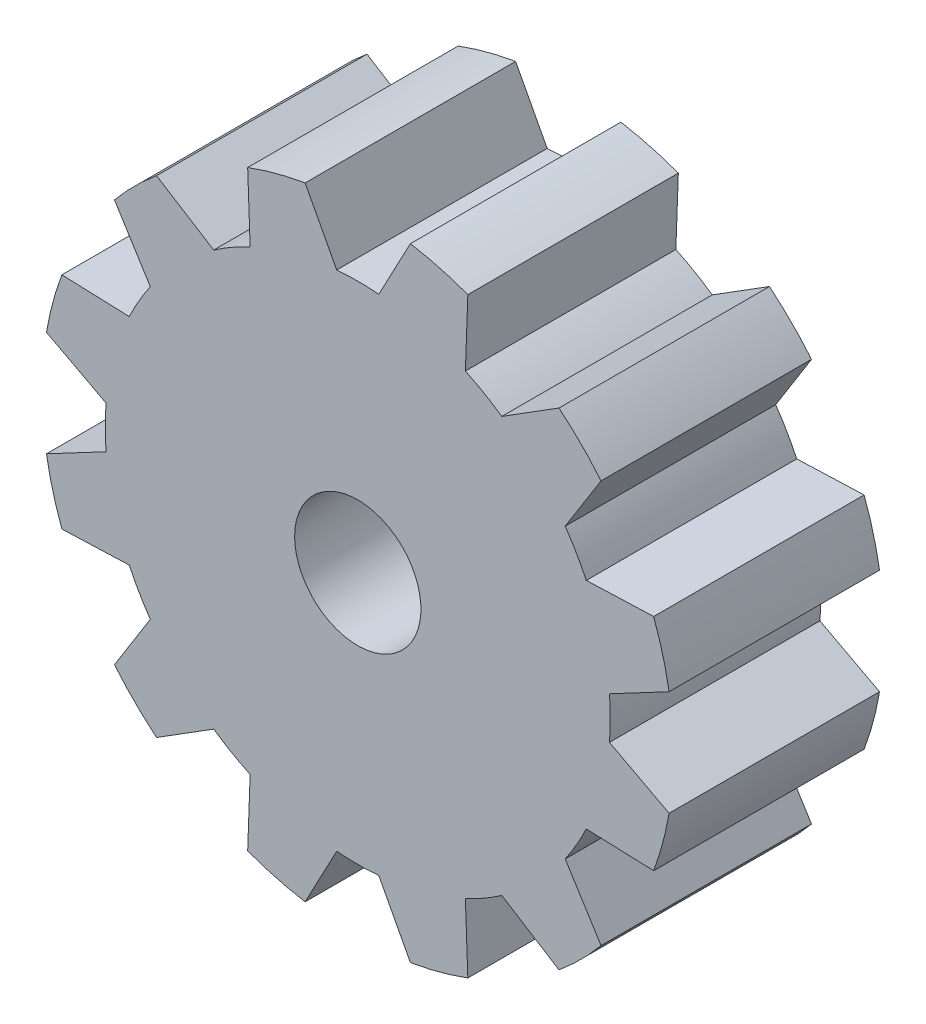
from build123d import *

# Parameters (mm, degrees)
SKETCH1_R           = 15
BOSS_EXTRUDE1_DEPTH = 10
CUT_EXTRUDE1_DEPTH  = 10
CIRPATTERN1_COUNT   = 12
SKETCH3_R           = 3
CUT_EXTRUDE2_DEPTH  = 11


with BuildPart() as part:
    # Sketch1 → Boss-Extrude1 (new body)
    with BuildSketch(Plane.XY):
        Circle(SKETCH1_R)
    extrude(amount=BOSS_EXTRUDE1_DEPTH)

    # Sketch2 → Cut-Extrude1 (cut)
    with BuildSketch(Plane.XY.offset(10)):
        with BuildLine():
            Line((-2.5, 14.790199458), (-1, 11.958260743))
            ThreePointArc((-1, 11.958260743), (0, 12), (1, 11.958260743))
            Line((1, 11.958260743), (2.5, 14.790199458))
            ThreePointArc((2.5, 14.790199458), (0, 15), (-2.5, 14.790199458))
        make_face()
    cut_extrude1 = extrude(amount=-CUT_EXTRUDE1_DEPTH, mode=Mode.SUBTRACT)

    # CirPattern1: Cut-Extrude1 ×12 about axis
    cirpattern1_axis = Axis((0, 0, 0), (0, 0, 1))
    for i in range(1, CIRPATTERN1_COUNT):
        add(cut_extrude1.rotate(cirpattern1_axis, i * 360 / CIRPATTERN1_COUNT), mode=Mode.SUBTRACT)

    # Sketch3 → Cut-Extrude2 (cut, through all)
    with BuildSketch(Plane(origin=(0, 0, 0), x_dir=(-1, 0, 0), z_dir=(0, 0, -1))):
        Circle(SKETCH3_R)
    extrude(amount=-CUT_EXTRUDE2_DEPTH, mode=Mode.SUBTRACT)


solid = part.part
